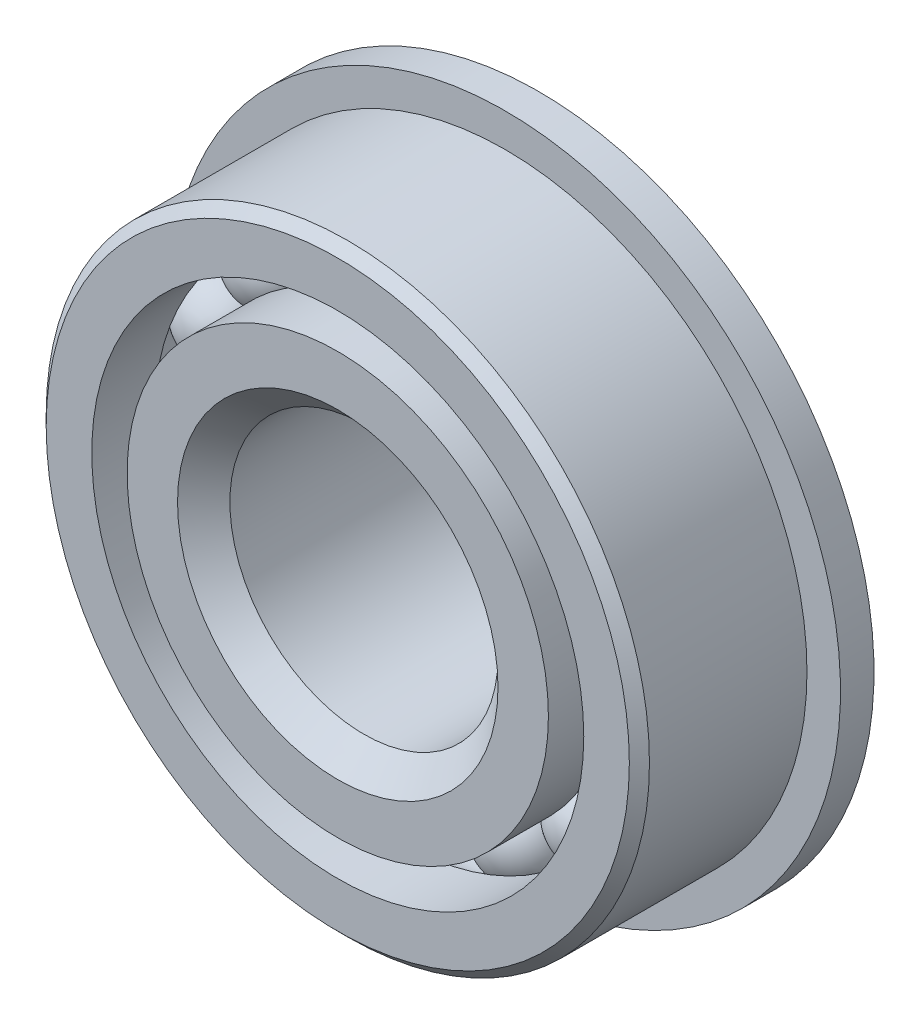
from build123d import *

# Parameters (mm, degrees)
CIRPATTERN1_COUNT = 16
SKETCH5_W         = 1.5875
SKETCH5_H         = 3.143271806


with BuildPart() as part:
    # Sketch1 → Revolve1 (revolve)
    with BuildSketch(Plane(origin=(0, 0, 0), x_dir=(0, 0, -1), z_dir=(1, 0, 0))):
        with BuildLine():
            Line((4.28625, 14.2875), (-4.28625, 14.2875))
            Line((-4.28625, 14.2875), (-4.7625, 13.81125))
            Line((-4.7625, 13.81125), (-4.7625, 11.652206387))
            Line((-4.7625, 11.652206387), (-1.799046401, 11.652206387))
            ThreePointArc((-1.799046401, 11.652206387), (0, 12.79921875), (1.799046401, 11.652206387))
            Line((1.799046401, 11.652206387), (4.7625, 11.652206387))
            Line((4.7625, 11.652206387), (4.7625, 13.81125))
            Line((4.7625, 13.81125), (4.28625, 14.2875))
        make_face()
    revolve(axis=Axis((0, 0, 4.7625), (0, 0, -1)))

    # Sketch5 → Revolve5 (revolve)
    with BuildSketch(Plane(origin=(0, 0, 0), x_dir=(0, 0, -1), z_dir=(1, 0, 0))):
        with Locations((3.96875, 14.303364097)):
            Rectangle(SKETCH5_W, SKETCH5_H)
    revolve(axis=Axis((0, 0, -6.35), (0, 0, 1)))


with BuildPart() as body_2:
    # Sketch2 → Revolve2 (revolve)
    with BuildSketch(Plane(origin=(0, 0, 0), x_dir=(0, 0, -1), z_dir=(1, 0, 0))):
        with BuildLine():
            Line((-4.7625, 9.977481113), (-1.799046401, 9.977481113))
            ThreePointArc((-1.799046401, 9.977481113), (-1.066794886, 9.141615489), (0, 8.83046875))
            Line((0, 8.83046875), (0, 7.590234375))
            Line((0, 7.590234375), (-3.568876631, 7.590234375))
            Line((-3.568876631, 7.590234375), (-4.7625, 8.783857744))
            Line((-4.7625, 8.783857744), (-4.7625, 9.977481113))
        make_face()
    revolve(axis=Axis((0, 0, 4.7625), (0, 0, -1)))

    # Sketch3 → Revolve3 (revolve)
    with BuildSketch(Plane(origin=(0, 0, 0), x_dir=(0, 0, -1), z_dir=(1, 0, 0))):
        with BuildLine():
            Line((-4.7625, 8.783857744), (-3.568876631, 7.590234375))
            Line((-3.568876631, 7.590234375), (0, 7.590234375))
            Line((0, 7.590234375), (0, 8.83046875))
            ThreePointArc((0, 8.83046875), (1.066794886, 9.141615489), (1.799046401, 9.977481113))
            Line((1.799046401, 9.977481113), (6.35, 9.977481113))
            Line((6.35, 9.977481113), (6.35, 6.82625))
            Line((6.35, 6.82625), (5.87375, 6.35))
            Line((5.87375, 6.35), (-3.522265625, 6.35))
            Line((-3.522265625, 6.35), (-4.7625, 7.590234375))
            Line((-4.7625, 7.590234375), (-4.7625, 8.783857744))
        make_face()
    revolve(axis=Axis((0, 0, 4.7625), (0, 0, -1)))


with BuildPart() as body_3:
    # Sketch4 → Revolve4 (revolve)
    with BuildSketch(Plane(origin=(0, 0, 0), x_dir=(0, 0, -1), z_dir=(1, 0, 0))):
        with BuildLine():
            Line((-1.984375, 10.81484375), (1.984375, 10.81484375))
            ThreePointArc((1.984375, 10.81484375), (0, 12.79921875), (-1.984375, 10.81484375))
        make_face()
    revolve(axis=Axis((0, 10.81484375, 1.984375), (0, 0, -1)))


with BuildPart() as cirpattern1_1:
    # CirPattern1: pattern copy
    add(body_3.part.rotate(Axis((0, 0, -4.7625), (0, 0, 1)), 1 * 360 / CIRPATTERN1_COUNT))


with BuildPart() as cirpattern1_2:
    # CirPattern1: pattern copy
    add(body_3.part.rotate(Axis((0, 0, -4.7625), (0, 0, 1)), 2 * 360 / CIRPATTERN1_COUNT))


with BuildPart() as cirpattern1_3:
    # CirPattern1: pattern copy
    add(body_3.part.rotate(Axis((0, 0, -4.7625), (0, 0, 1)), 3 * 360 / CIRPATTERN1_COUNT))


with BuildPart() as cirpattern1_4:
    # CirPattern1: pattern copy
    add(body_3.part.rotate(Axis((0, 0, -4.7625), (0, 0, 1)), 4 * 360 / CIRPATTERN1_COUNT))


with BuildPart() as cirpattern1_5:
    # CirPattern1: pattern copy
    add(body_3.part.rotate(Axis((0, 0, -4.7625), (0, 0, 1)), 5 * 360 / CIRPATTERN1_COUNT))


with BuildPart() as cirpattern1_6:
    # CirPattern1: pattern copy
    add(body_3.part.rotate(Axis((0, 0, -4.7625), (0, 0, 1)), 6 * 360 / CIRPATTERN1_COUNT))


with BuildPart() as cirpattern1_7:
    # CirPattern1: pattern copy
    add(body_3.part.rotate(Axis((0, 0, -4.7625), (0, 0, 1)), 7 * 360 / CIRPATTERN1_COUNT))


with BuildPart() as cirpattern1_8:
    # CirPattern1: pattern copy
    add(body_3.part.rotate(Axis((0, 0, -4.7625), (0, 0, 1)), 8 * 360 / CIRPATTERN1_COUNT))


with BuildPart() as cirpattern1_9:
    # CirPattern1: pattern copy
    add(body_3.part.rotate(Axis((0, 0, -4.7625), (0, 0, 1)), 9 * 360 / CIRPATTERN1_COUNT))


with BuildPart() as cirpattern1_10:
    # CirPattern1: pattern copy
    add(body_3.part.rotate(Axis((0, 0, -4.7625), (0, 0, 1)), 10 * 360 / CIRPATTERN1_COUNT))


with BuildPart() as cirpattern1_11:
    # CirPattern1: pattern copy
    add(body_3.part.rotate(Axis((0, 0, -4.7625), (0, 0, 1)), 11 * 360 / CIRPATTERN1_COUNT))


with BuildPart() as cirpattern1_12:
    # CirPattern1: pattern copy
    add(body_3.part.rotate(Axis((0, 0, -4.7625), (0, 0, 1)), 12 * 360 / CIRPATTERN1_COUNT))


with BuildPart() as cirpattern1_13:
    # CirPattern1: pattern copy
    add(body_3.part.rotate(Axis((0, 0, -4.7625), (0, 0, 1)), 13 * 360 / CIRPATTERN1_COUNT))


with BuildPart() as cirpattern1_14:
    # CirPattern1: pattern copy
    add(body_3.part.rotate(Axis((0, 0, -4.7625), (0, 0, 1)), 14 * 360 / CIRPATTERN1_COUNT))


with BuildPart() as cirpattern1_15:
    # CirPattern1: pattern copy
    add(body_3.part.rotate(Axis((0, 0, -4.7625), (0, 0, 1)), 15 * 360 / CIRPATTERN1_COUNT))


solid = Compound([part.part, body_2.part, body_3.part, cirpattern1_1.part, cirpattern1_2.part, cirpattern1_3.part, cirpattern1_4.part, cirpattern1_5.part, cirpattern1_6.part, cirpattern1_7.part, cirpattern1_8.part, cirpattern1_9.part, cirpattern1_10.part, cirpattern1_11.part, cirpattern1_12.part, cirpattern1_13.part, cirpattern1_14.part, cirpattern1_15.part])
